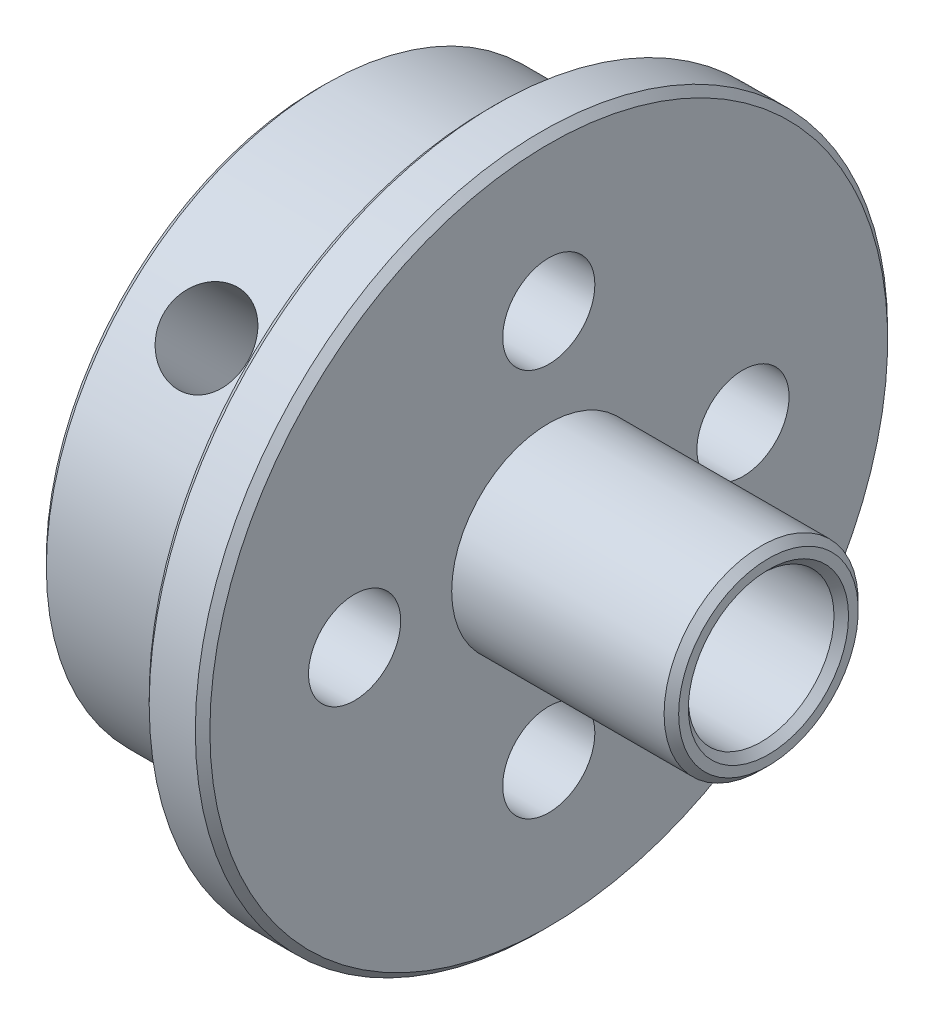
from build123d import *

# Parameters (mm, degrees)
F_6_CLEARANCE_HOLE1_D     = 3.7973
BOSS_EXTRUDE1_START       = 10
SKETCH4_R                 = 1.25
BOSS_EXTRUDE1_DEPTH       = 1.5
F_8_32_TAPPED_HOLE1_D     = 3.4544
F_8_32_TAPPED_HOLE1_DEPTH = 10.708
F_8_32_TAPPED_HOLE1_TIP   = 1.037806461
MOVE_FACE1_BY             = 6.55
CHAMFER1_SIZE             = 0.3


with BuildPart() as part:
    # Sketch1 → Revolve1 (revolve)
    with BuildSketch(Plane.XY):
        Polygon((-9.5, 3), (2.5, 3), (2.5, 4), (0, 4), (0, 14.2621), (-2.5, 14.2621), (-2.5, 11.5), (-9.5, 11.5), align=None)
    revolve(axis=Axis((0, 0, 0), (1, 0, 0)))

    # 6 Clearance Hole1 (through all)
    with Locations(Plane(origin=(0, 0, 0), x_dir=(0, 0, -1), z_dir=(1, 0, 0))):
        with Locations((-8, 0), (0, 8), (0, -8), (8, 0)):
            Hole(F_6_CLEARANCE_HOLE1_D / 2)

    # Sketch4 → Boss-Extrude1 (add)
    with BuildSketch(Plane(origin=(0, 0, 0), x_dir=(-1, 0, 0), z_dir=(0, 0.7071067811865464, 0.7071067811865488)).offset(BOSS_EXTRUDE1_START)):
        with Locations((6, 0)):
            Circle(SKETCH4_R)
    extrude(amount=BOSS_EXTRUDE1_DEPTH)

    # 8-32 Tapped Hole1
    with Locations(Plane(origin=(0, 8.131727984, 8.131727984), x_dir=(1, 0, 0), z_dir=(0, 0.7071067811865465, 0.7071067811865487))):
        with Locations((-6, 0)):
            Hole(F_8_32_TAPPED_HOLE1_D / 2, depth=F_8_32_TAPPED_HOLE1_DEPTH)
            with Locations((0, 0, -(F_8_32_TAPPED_HOLE1_DEPTH + F_8_32_TAPPED_HOLE1_TIP / 2))):  # 118° drill point
                Cone(0, F_8_32_TAPPED_HOLE1_D / 2, F_8_32_TAPPED_HOLE1_TIP, mode=Mode.SUBTRACT)

    # Move Face1: a face moved outward by 6.55
    extrude(part.faces().sort_by_distance((2.5, 0, -3.2))[0], amount=MOVE_FACE1_BY, dir=(1, 0, 0))

    # Chamfer1
    chamfer1_edges = [part.edges().sort_by_distance(p)[0] for p in [
        (-9.5, -11.5, 0),
        (-2.5, -14.2621, 0),
        (0, -14.2621, 0),
        (9.05, -3, 0),
        (9.05, -4, 0),
        (-9.5, -3, 0),
    ]]
    chamfer(chamfer1_edges, length=CHAMFER1_SIZE)


solid = part.part
